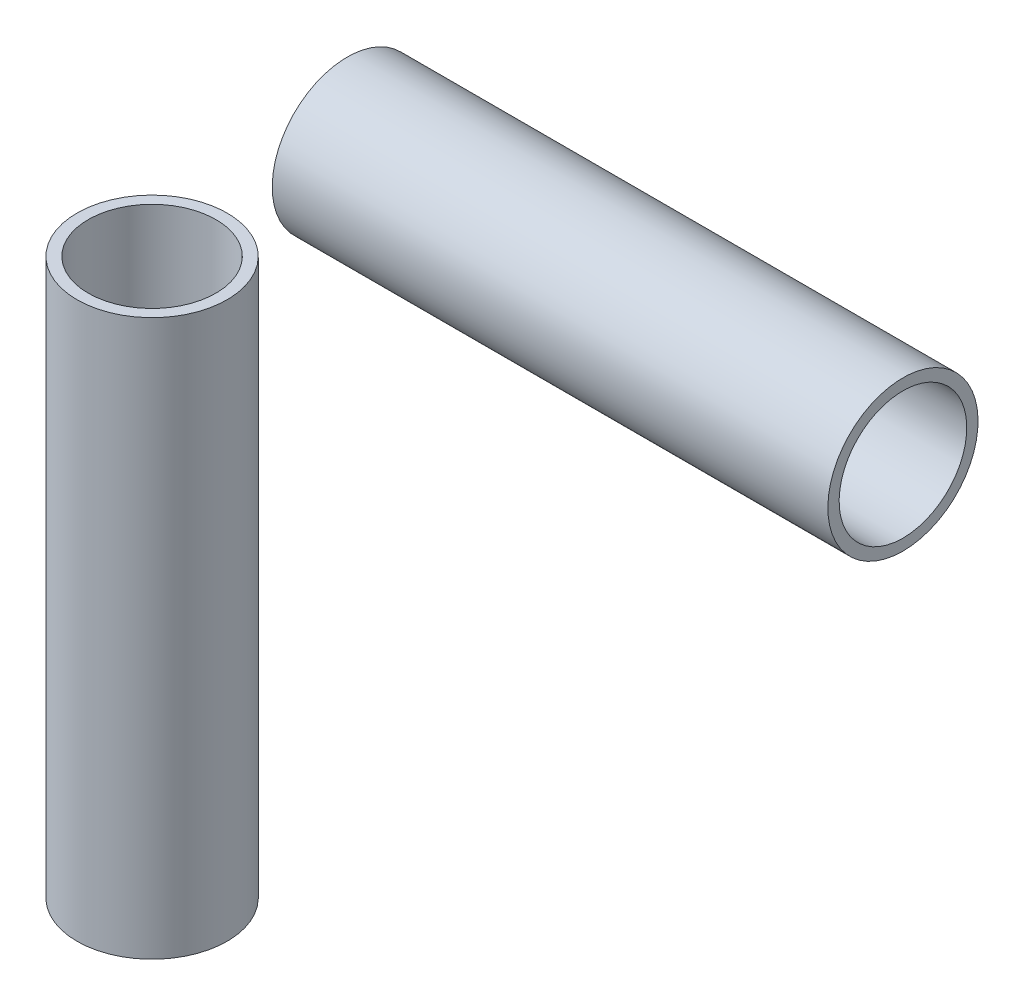
from build123d import *

# Parameters (mm, degrees)
TUBE_METRIQUE_ROUL_SOUD_R                    = 10
TUBE_METRIQUE_ROUL_SOUD_R_2                  = 8.5
TUBES_METRIQUES_ROUL_S_SOUD_S_TUBE_002_DEPTH = 74
TUBE_METRIQUE_ROUL_SOUD_ON_SEGMENT_2_R       = 10
TUBE_METRIQUE_ROUL_SOUD_ON_SEGMENT_2_R_2     = 8.5
TUBES_METRIQUES_ROUL_S_SOUD_S_TUBE_2_DEPTH   = 74


with BuildPart() as part:
    # Tube Metrique roulé-soudé → Tubes metriques roulés soudés TUBE Ø 0020 X 1,5 MM(1) (new body)
    with BuildSketch(Plane(origin=(0, 0, 0), x_dir=(1, 0, 0), z_dir=(0, 1, 0))):
        Circle(TUBE_METRIQUE_ROUL_SOUD_R)
        Circle(TUBE_METRIQUE_ROUL_SOUD_R_2, mode=Mode.SUBTRACT)
    extrude(amount=TUBES_METRIQUES_ROUL_S_SOUD_S_TUBE_002_DEPTH)


with BuildPart() as body_2:
    # Tube Metrique roulé-soudé on segment 2 (carried to segment 2) → Tubes metriques roul_s soud_s TUBE _ 2 (new body)
    with BuildSketch(Plane(origin=(26, 100, 0), x_dir=(0, -1, 0), z_dir=(1, 0, 0))):
        Circle(TUBE_METRIQUE_ROUL_SOUD_ON_SEGMENT_2_R)
        Circle(TUBE_METRIQUE_ROUL_SOUD_ON_SEGMENT_2_R_2, mode=Mode.SUBTRACT)
    extrude(amount=TUBES_METRIQUES_ROUL_S_SOUD_S_TUBE_2_DEPTH)


solid = Compound([part.part, body_2.part])
